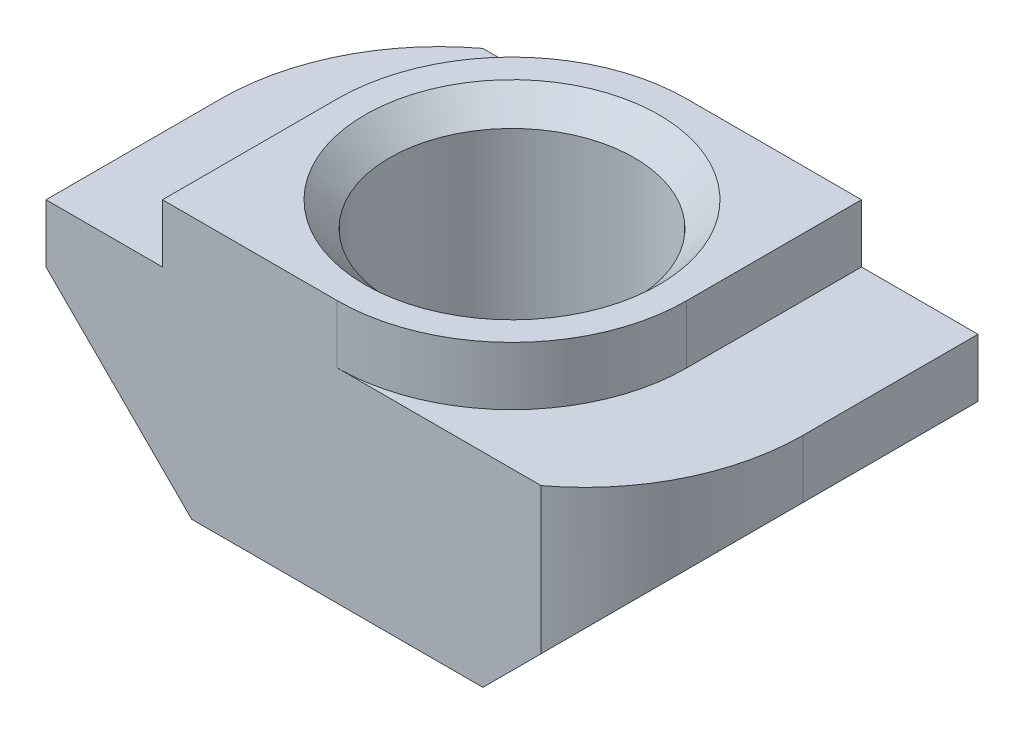
from build123d import *

# Parameters (mm, degrees)
BOSS_EXTRUDE1_DEPTH             = 6
CUT_EXTRUDE1_DEPTH              = 1
CUT_EXTRUDE2_DEPTH              = 4.5
M5X0_8_TAPPED_HOLE1_D           = 4.2
M5X0_8_TAPPED_HOLE1_CSINK_D     = 5.05
M5X0_8_TAPPED_HOLE1_CSINK_ANGLE = 90


with BuildPart() as part:
    # Sketch1 → Boss-Extrude1 (new body)
    with BuildSketch(Plane.XY):
        Polygon((-3, 4.5), (3, 4.5), (3, 3.5), (5, 3.5), (5, 2.5), (2.5, 0), (-2.5, 0), (-5, 2.5), (-5, 3.5), (-3, 3.5), align=None)
    extrude(amount=BOSS_EXTRUDE1_DEPTH)

    # Sketch2 → Cut-Extrude1 (cut)
    with BuildSketch(Plane(origin=(0, 4.5, 0), x_dir=(1, 0, 0), z_dir=(0, 1, 0))):
        with BuildLine():
            Line((0, -6), (3, -6))
            Line((3, -6), (3, -3))
            ThreePointArc((3, -3), (2.121320344, -5.121320344), (0, -6))
        make_face()
        with BuildLine():
            Line((0, 0), (-3, 0))
            Line((-3, 0), (-3, -3))
            ThreePointArc((-3, -3), (-2.121320344, -0.878679656), (0, 0))
        make_face()
    extrude(amount=-CUT_EXTRUDE1_DEPTH, mode=Mode.SUBTRACT)

    # Sketch3 → Cut-Extrude2 (cut, through all)
    with BuildSketch(Plane(origin=(0, 3.5, 0), x_dir=(1, 0, 0), z_dir=(0, 1, 0))):
        with BuildLine():
            Line((5, -3), (5, -6))
            Line((5, -6), (3.5, -6))
            ThreePointArc((3.5, -6), (4.604101966, -4.677050983), (5, -3))
        make_face()
        with BuildLine():
            Line((-5, 0), (-3.5, 0))
            ThreePointArc((-3.5, 0), (-4.604101966, -1.322949017), (-5, -3))
            Line((-5, -3), (-5, 0))
        make_face()
    extrude(amount=-CUT_EXTRUDE2_DEPTH, mode=Mode.SUBTRACT)

    # M5x0.8 Tapped Hole1 (through all)
    with Locations(Plane(origin=(0, 4.5, 0), x_dir=(1, 0, 0), z_dir=(0, 1, 0))):
        with Locations((0, -3)):
            CounterSinkHole(M5X0_8_TAPPED_HOLE1_D / 2, M5X0_8_TAPPED_HOLE1_CSINK_D / 2, counter_sink_angle=M5X0_8_TAPPED_HOLE1_CSINK_ANGLE)


solid = part.part
